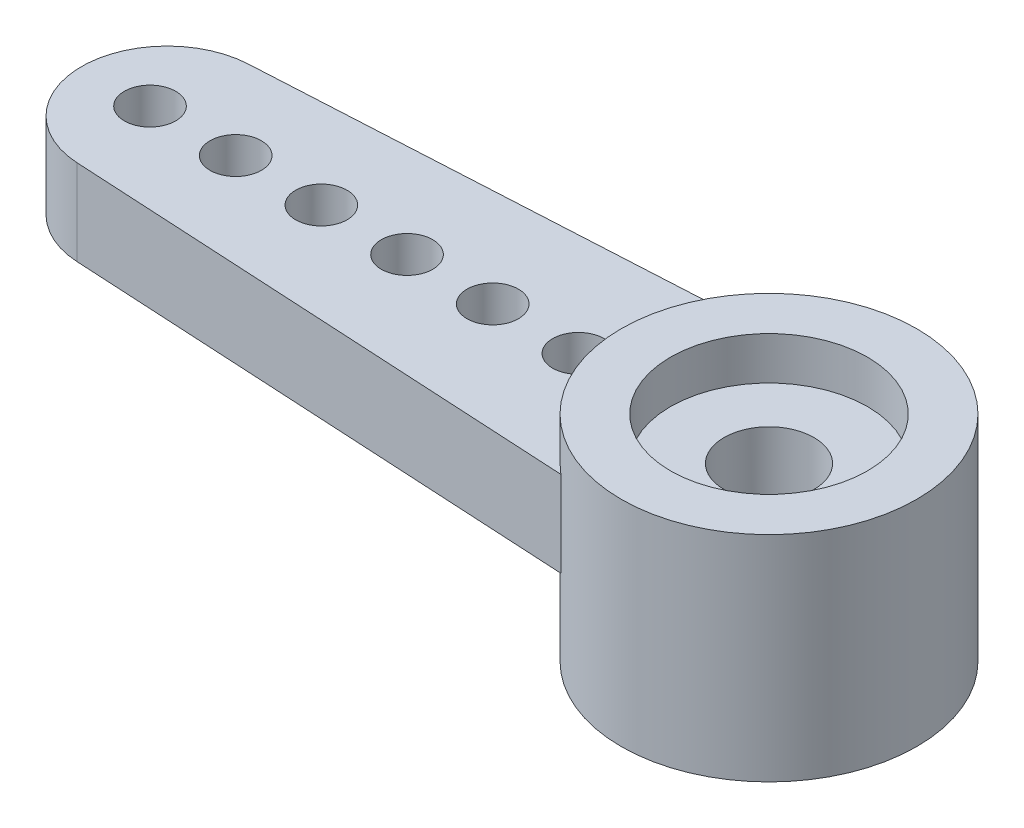
from build123d import *

# Parameters (mm, degrees)
RESSALTO_EXTRUS_O1_DEPTH = 2
ESBO_O2_R                = 3.45
RESSALTO_EXTRUS_O2_DEPTH = 3
FURO4_D                  = 1.2
PADR_O_LINEAR1_COUNT     = 6
PADR_O_LINEAR1_PITCH     = 2
FURO1_D                  = 4.95
FURO1_DEPTH              = 2
FURO2_D                  = 4.6
FURO2_DEPTH              = 1
FURO3_D                  = 2.1
RESSALTO_EXTRUS_O3_DEPTH = 2
PADR_OCIRCULAR1_COUNT    = 60
EXTRUDE_1_DEPTH          = 1
CUT_EXTRUDE_1_DEPTH      = 1
SKETCH_3_R               = 0.6
CUT_EXTRUDE_2_DEPTH      = 5


with BuildPart() as part:
    # Esboço1 → Ressalto-extrusão1 (new body)
    with BuildSketch(Plane(origin=(0, 0, 0), x_dir=(1, 0, 0), z_dir=(0, 1, 0))):
        with BuildLine():
            Line((-14.159122, 1.997021), (-2.209072, 2.65))
            ThreePointArc((-2.209072, 2.65), (3.45, 0), (-2.209072, -2.65))
            Line((-2.209072, -2.65), (-14.159122, -1.997021))
            ThreePointArc((-14.159122, -1.997021), (-16.05, 0), (-14.159122, 1.997021))
        make_face()
    extrude(amount=-RESSALTO_EXTRUS_O1_DEPTH)

    # Esboço2 → Ressalto-extrusão2 (add)
    with BuildSketch(Plane.XZ.offset(2)):
        Circle(ESBO_O2_R)
    extrude(amount=RESSALTO_EXTRUS_O2_DEPTH)

    # Furo4 (through all)
    with Locations(Plane(origin=(0, 0, 0), x_dir=(1, 0, 0), z_dir=(0, 1, 0))):
        with Locations((-14.45, 0)):
            furo4 = Hole(FURO4_D / 2)

    # Padrão linear1: Furo4 ×6
    with Locations(*[(i * PADR_O_LINEAR1_PITCH, 0, 0) for i in range(1, PADR_O_LINEAR1_COUNT)]):
        add(furo4, mode=Mode.SUBTRACT)

    # Furo1
    with Locations(Plane(origin=(0, -5, 0), x_dir=(-1, 0, 0), z_dir=(0, -1, 0))):
        with Locations((0, 0)):
            Hole(FURO1_D / 2, depth=FURO1_DEPTH)

    # Furo2
    with Locations(Plane(origin=(0, 0, 0), x_dir=(1, 0, 0), z_dir=(0, 1, 0))):
        with Locations((0, 0)):
            Hole(FURO2_D / 2, depth=FURO2_DEPTH)

    # Furo3 (through all)
    with Locations(Plane(origin=(0, 0, 0), x_dir=(1, 0, 0), z_dir=(0, 1, 0))):
        with Locations((0, 0)):
            Hole(FURO3_D / 2)

    # Esboço11 → Ressalto-extrusão3 (add)
    with BuildSketch(Plane.XZ.offset(5)):
        with BuildLine():
            Line((-0.098057, 2.473057), (0, 2.375))
            Line((0, 2.375), (0.098057, 2.473057))
            ThreePointArc((0.098057, 2.473057), (0, 2.475), (-0.098057, 2.473057))
        make_face()
    ressalto_extrus_o3 = extrude(amount=-RESSALTO_EXTRUS_O3_DEPTH)

    # PadrãoCircular1: Ressalto-extrusão3 ×60 about axis
    padr_ocircular1_axis = Axis((0, 0, 0), (0, 1, 0))
    for i in range(1, PADR_OCIRCULAR1_COUNT):
        add(ressalto_extrus_o3.rotate(padr_ocircular1_axis, i * 360 / PADR_OCIRCULAR1_COUNT))

    # 草图1 → 凸台-拉伸1 (add)
    with BuildSketch(Plane.XZ.offset(2)):
        with BuildLine():
            Line((-2.209072, 2.65), (-14.159122, 1.997021))
            ThreePointArc((-14.159122, 1.997021), (-16.05, 0), (-14.159122, -1.997021))
            Line((-14.159122, -1.997021), (-2.209072, -2.65))
            ThreePointArc((-2.209072, -2.65), (-3.45, 0), (-2.209072, 2.65))
        make_face()
    extrude(amount=EXTRUDE_1_DEPTH)

    # 草图2 → 切除-拉伸1 (cut)
    with BuildSketch(Plane(origin=(0, 0, 0), x_dir=(1, 0, 0), z_dir=(0, 1, 0))):
        with BuildLine():
            Line((-14.159122, -1.997021), (-2.209072, -2.65))
            ThreePointArc((-2.209072, -2.65), (-3.45, 0), (-2.209072, 2.65))
            Line((-2.209072, 2.65), (-14.159122, 1.997021))
            ThreePointArc((-14.159122, 1.997021), (-16.05, 0), (-14.159122, -1.997021))
        make_face()
    extrude(amount=-CUT_EXTRUDE_1_DEPTH, mode=Mode.SUBTRACT)

    # 草图3 → 切除-拉伸2 (cut, through all)
    with BuildSketch(Plane(origin=(0, -1, 0), x_dir=(1, 0, 0), z_dir=(0, 1, 0))):
        with Locations((-4.45, 0)):
            Circle(SKETCH_3_R)
        with Locations((-6.45, 0)):
            Circle(SKETCH_3_R)
        with Locations((-8.45, 0)):
            Circle(SKETCH_3_R)
        with Locations((-14.45, 0)):
            Circle(SKETCH_3_R)
        with Locations((-10.45, 0)):
            Circle(SKETCH_3_R)
        with Locations((-12.45, 0)):
            Circle(SKETCH_3_R)
    extrude(amount=-CUT_EXTRUDE_2_DEPTH, mode=Mode.SUBTRACT)


solid = part.part
